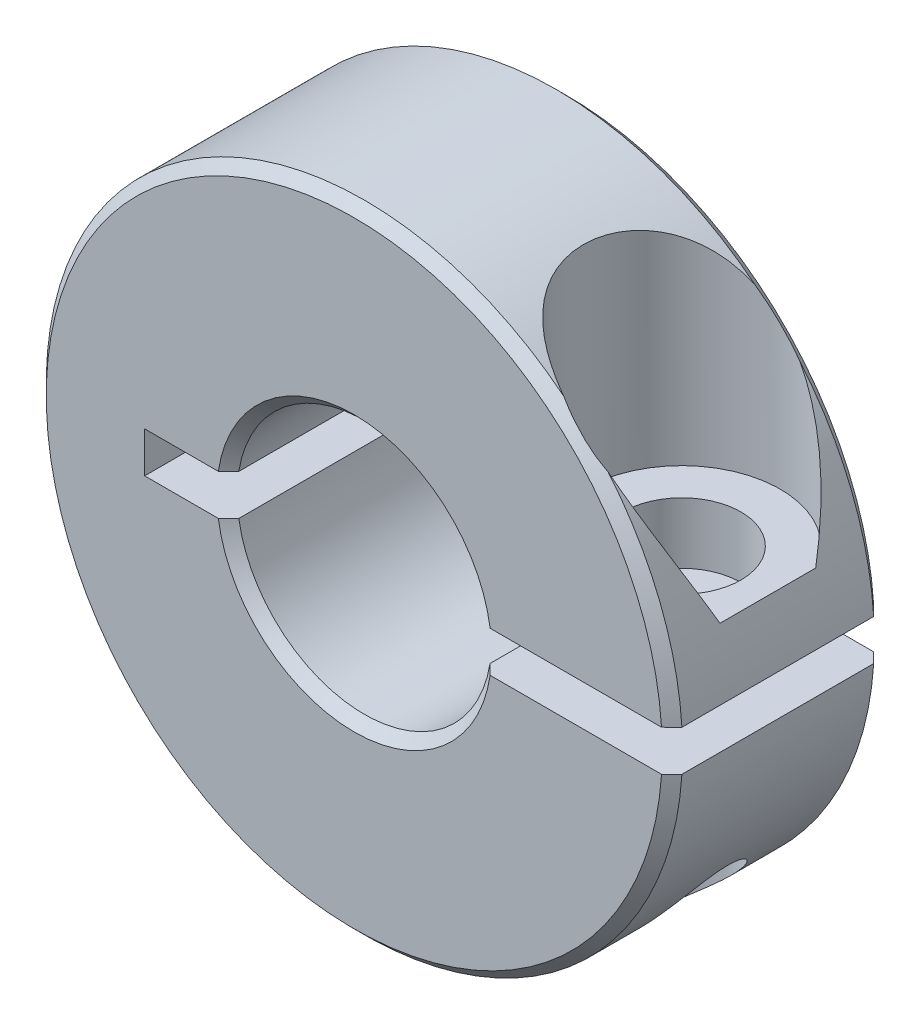
from build123d import *

# Parameters (mm, degrees)
BOSS_EXTRUDE1_DEPTH = 3.96875
SKETCH4_W           = 1.7272
SKETCH4_H           = 11.14425
CHAMFER1_SIZE       = 0.381


with BuildPart() as part:
    # Sketch1 → Boss-Extrude1 (new, symmetric)
    with BuildSketch(Plane.XY):
        with BuildLine():
            Line((-7.84225, 0.762), (-4.701144781, 0.762))
            ThreePointArc((-4.701144781, 0.762), (0, 4.7625), (4.701144781, 0.762))
            Line((4.701144781, 0.762), (11.88184098, 0.762))
            ThreePointArc((11.88184098, 0.762), (-11.90625, 0), (11.88184098, -0.762))
            Line((11.88184098, -0.762), (4.701144781, -0.762))
            ThreePointArc((4.701144781, -0.762), (0, -4.7625), (-4.701144781, -0.762))
            Line((-4.701144781, -0.762), (-7.84225, -0.762))
            Line((-7.84225, -0.762), (-7.84225, 0.762))
        make_face()
    extrude(amount=BOSS_EXTRUDE1_DEPTH, both=True)

    # Sketch4 → 8-32 Tapped Hole1 (revolve, cut)
    with BuildSketch(Plane(origin=(8.29149288, -0.762, 0), x_dir=(0, 0, 1), z_dir=(1, 0, 0))):
        with Locations((0.8636, 5.572125)):
            Rectangle(SKETCH4_W, SKETCH4_H)
    revolve(axis=Axis((8.29149288, 5.588, 0), (0, -1, 0)), mode=Mode.SUBTRACT)

    # Chamfer1
    chamfer1_edges = [part.edges().sort_by_distance(p)[0] for p in [
        (-11.90625, 0, -3.96875),
        (0, -4.7625, -3.96875),
        (0, 4.7625, -3.96875),
        (-11.90625, 0, 3.96875),
        (0, -4.7625, 3.96875),
        (0, 4.7625, 3.96875),
    ]]
    chamfer(chamfer1_edges, length=CHAMFER1_SIZE)

    # Sketch10 → Cut-Revolve1 (revolve, cut)
    with BuildSketch(Plane.XY):
        Polygon((8.293387365, 0.762), (10.50129288, 0.762), (10.50129288, 3.048), (11.97449288, 3.048), (11.97449288, 11.90625), (8.293387365, 11.90625), align=None)
    revolve(axis=Axis((8.29149288, -0.762, 0), (0, -1, 0)), mode=Mode.SUBTRACT)


with BuildPart() as cut_revolve1_piece_1:
    # of the separate pieces the step leaves, piece 1, a body of its own (cut_revolve1_pieces)
    add(part.part.solids().sort_by_distance((-5.086742401, -0.762, -3.96875))[0])


with BuildPart() as cut_revolve1_piece_2:
    # of the separate pieces the step leaves, piece 2, a body of its own (cut_revolve1_pieces)
    add(part.part.solids().sort_by_distance((8.293387365, 0.762, 0))[0])


solid = Compound([cut_revolve1_piece_1.part, cut_revolve1_piece_2.part])
